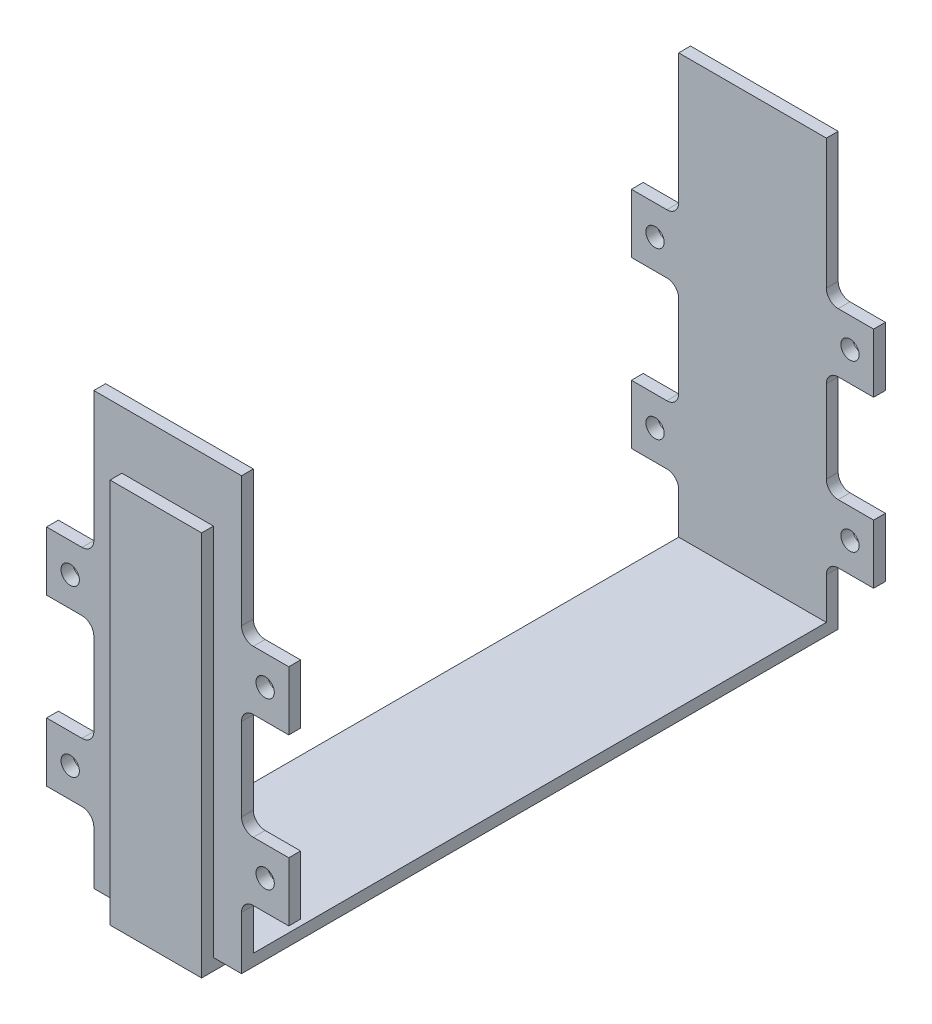
from build123d import *

# Parameters (mm, degrees)
SKETCH1_W           = 105
SKETCH1_H           = 4
SKETCH1_W_2         = 2
SKETCH1_H_2         = 9.75
BOSS_EXTRUDE1_DEPTH = 12.5
SKETCH2_W           = 8
SKETCH2_H           = 10
SKETCH2_R           = 1.55
BOSS_EXTRUDE2_DEPTH = 2
SKETCH4_W           = 8
SKETCH4_H           = 10
SKETCH4_R           = 1.55
BOSS_EXTRUDE3_DEPTH = 2
SKETCH5_W           = 101
SKETCH5_H           = 2
CUT_EXTRUDE1_DEPTH  = 4.75
SKETCH6_W           = 101
SKETCH6_H           = 2
CUT_EXTRUDE2_DEPTH  = 4.75
FILLET1_R           = 2


with BuildPart() as part:
    # Sketch1 → Boss-Extrude1 (new body, symmetric)
    with BuildSketch(Plane(origin=(0, 0, 0), x_dir=(0, 0, -1), z_dir=(1, 0, 0))):
        Rectangle(SKETCH1_W, SKETCH1_H)
        Polygon((-52.5, 63.25), (-52.5, 2), (-48.5, 2), (-48.5, 63.25), (-50.5, 63.25), align=None)
        Polygon((48.5, 63.25), (48.5, 2), (52.5, 2), (52.5, 63.25), (50.5, 63.25), align=None)
        with Locations((-49.5, 68.125)):
            Rectangle(SKETCH1_W_2, SKETCH1_H_2)
        with Locations((49.5, 68.125)):
            Rectangle(SKETCH1_W_2, SKETCH1_H_2)
    extrude(amount=BOSS_EXTRUDE1_DEPTH, both=True)

    # Sketch2 → Boss-Extrude2 (add)
    with BuildSketch(Plane.XY.offset(-48.5)):
        with Locations((-16.5, 16)):
            Rectangle(SKETCH2_W, SKETCH2_H)
        with Locations((-16.5, 16)):
            Circle(SKETCH2_R, mode=Mode.SUBTRACT)
        with Locations((-16.5, 44)):
            Rectangle(SKETCH2_W, SKETCH2_H)
        with Locations((-16.5, 44)):
            Circle(SKETCH2_R, mode=Mode.SUBTRACT)
        with Locations((16.5, 16)):
            Rectangle(SKETCH2_W, SKETCH2_H)
        with Locations((16.5, 16)):
            Circle(SKETCH2_R, mode=Mode.SUBTRACT)
        with Locations((16.5, 44)):
            Rectangle(SKETCH2_W, SKETCH2_H)
        with Locations((16.5, 44)):
            Circle(SKETCH2_R, mode=Mode.SUBTRACT)
    extrude(amount=-BOSS_EXTRUDE2_DEPTH)

    # Sketch4 → Boss-Extrude3 (add)
    with BuildSketch(Plane(origin=(0, 0, 48.5), x_dir=(-1, 0, 0), z_dir=(0, 0, -1))):
        with Locations((-16.5, 16)):
            Rectangle(SKETCH4_W, SKETCH4_H)
        with Locations((-16.5, 16)):
            Circle(SKETCH4_R, mode=Mode.SUBTRACT)
        with Locations((-16.5, 44)):
            Rectangle(SKETCH4_W, SKETCH4_H)
        with Locations((-16.5, 44)):
            Circle(SKETCH4_R, mode=Mode.SUBTRACT)
        with Locations((16.5, 16)):
            Rectangle(SKETCH4_W, SKETCH4_H)
        with Locations((16.5, 16)):
            Circle(SKETCH4_R, mode=Mode.SUBTRACT)
        with Locations((16.5, 44)):
            Rectangle(SKETCH4_W, SKETCH4_H)
        with Locations((16.5, 44)):
            Circle(SKETCH4_R, mode=Mode.SUBTRACT)
    extrude(amount=-BOSS_EXTRUDE3_DEPTH)

    # Sketch5 → Cut-Extrude1 (cut)
    with BuildSketch(Plane.ZY.offset(12.5)):
        Polygon((-50.5, 63.25), (-52.5, 63.25), (-52.5, -2), (-50.5, -2), (-50.5, 0), (-50.5, 11), (-50.5, 21), (-50.5, 39), (-50.5, 49), align=None)
        with Locations((0, -1)):
            Rectangle(SKETCH5_W, SKETCH5_H)
        Polygon((50.5, 0), (50.5, -2), (52.5, -2), (52.5, 63.25), (50.5, 63.25), (50.5, 49), (50.5, 39), (50.5, 21), (50.5, 11), align=None)
    extrude(amount=-CUT_EXTRUDE1_DEPTH, mode=Mode.SUBTRACT)

    # Sketch6 → Cut-Extrude2 (cut)
    with BuildSketch(Plane(origin=(12.5, 0, 0), x_dir=(0, 0, -1), z_dir=(1, 0, 0))):
        Polygon((-50.5, 0), (-50.5, 63.25), (-52.5, 63.25), (-52.5, -2), (-50.5, -2), align=None)
        with Locations((0, -1)):
            Rectangle(SKETCH6_W, SKETCH6_H)
        Polygon((50.5, 63.25), (50.5, 0), (50.5, -2), (52.5, -2), (52.5, 63.25), align=None)
    extrude(amount=-CUT_EXTRUDE2_DEPTH, mode=Mode.SUBTRACT)

    # Fillet1
    fillet1_edges = [part.edges().sort_by_distance(p)[0] for p in [
        (12.5, 21, 49.5),
        (12.5, 11, 49.5),
        (12.5, 49, 49.5),
        (12.5, 39, 49.5),
        (-12.5, 11, 49.5),
        (-12.5, 21, 49.5),
        (-12.5, 39, 49.5),
        (-12.5, 49, 49.5),
        (-12.5, 21, -49.5),
        (-12.5, 11, -49.5),
        (-12.5, 49, -49.5),
        (-12.5, 39, -49.5),
        (12.5, 11, -49.5),
        (12.5, 21, -49.5),
        (12.5, 39, -49.5),
        (12.5, 49, -49.5),
    ]]
    fillet(fillet1_edges, radius=FILLET1_R)


solid = part.part
